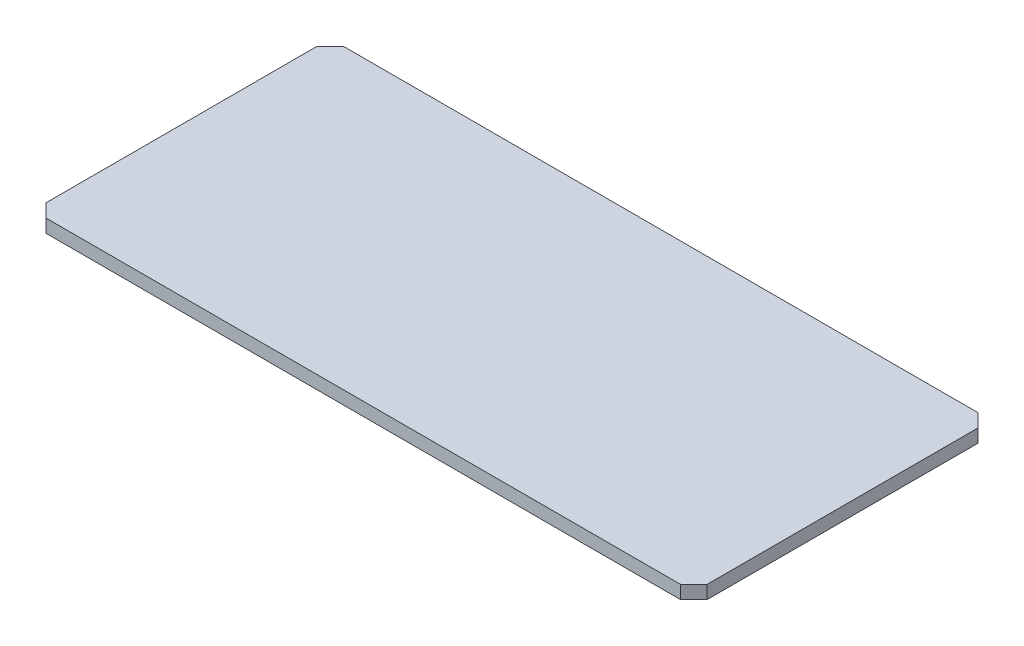
from build123d import *

# Parameters (mm, degrees)
SKETCH1_W                 = 254
SKETCH1_H                 = 114.3
BOSS_EXTRUDE1_DEPTH       = 5.08
CHAMFER1_SIZE             = 5.08
BOSS_EXTRUDE3_START       = -127
BOSS_EXTRUDE3_DEPTH       = 38.1
BOSS_EXTRUDE4_DEPTH       = 2.54
SKETCH6_R                 = 3
BOSS_EXTRUDE5_DEPTH       = 6
SKETCH12_R                = 3
SKETCH12_R_2              = 3.5
BOSS_EXTRUDE7_DEPTH       = 6
F_3_0MM_DOWEL_HOLE1_D     = 3
F_3_0MM_DOWEL_HOLE1_DEPTH = 5.08
SKETCH13_W                = 114.3
SKETCH13_H                = 11.500997776
CUT_EXTRUDE1_DEPTH        = 255


with BuildPart() as part:
    # Sketch1 → Boss-Extrude1 (new body)
    with BuildSketch(Plane(origin=(0, 0, 0), x_dir=(1, 0, 0), z_dir=(0, 1, 0))):
        with Locations((-127, 57.15)):
            Rectangle(SKETCH1_W, SKETCH1_H)
    extrude(amount=BOSS_EXTRUDE1_DEPTH)

    # Chamfer1
    chamfer1_edges = [part.edges().sort_by_distance(p)[0] for p in [
        (0, 2.54, 0),
        (-254, 2.54, 0),
        (-254, 2.54, -114.3),
        (0, 2.54, -114.3),
    ]]
    chamfer(chamfer1_edges, length=CHAMFER1_SIZE)

    # Sketch3 → Boss-Extrude3 (add, symmetric)
    with BuildSketch(Plane(origin=(0, 0, 0), x_dir=(0, 0, -1), z_dir=(1, 0, 0)).offset(BOSS_EXTRUDE3_START)):
        Polygon((2.667, 5.08), (2.667, 6.35), (2.032, 7.62), (2.667, 8.89), (3.937, 8.89), (3.937, 5.08), align=None)
    boss_extrude3 = extrude(amount=BOSS_EXTRUDE3_DEPTH, both=True)

    # Mirror1: Boss-Extrude3 across plane
    add(boss_extrude3.mirror(Plane.XY.offset(-57.15)))

    # Sketch4 → Boss-Extrude4 (add)
    with BuildSketch(Plane(origin=(0, 5.08, 0), x_dir=(1, 0, 0), z_dir=(0, 1, 0))):
        Polygon((-6.184707571, 111.633), (-247.815292429, 111.633), (-251.333, 108.115292429), (-251.333, 6.184707571), (-247.815292429, 2.667), (-6.184707571, 2.667), (-2.667, 6.184707571), (-2.667, 108.115292429), align=None)
        Polygon((-7.247331044, 109.0676), (-246.752668956, 109.0676), (-248.7676, 107.052668956), (-248.7676, 7.247331044), (-246.752668956, 5.2324), (-7.247331044, 5.2324), (-5.2324, 7.247331044), (-5.2324, 107.052668956), align=None, mode=Mode.SUBTRACT)
    extrude(amount=BOSS_EXTRUDE4_DEPTH)

    # Sketch6 → Boss-Extrude5 (add)
    with BuildSketch(Plane(origin=(0, 5.08, 0), x_dir=(1, 0, 0), z_dir=(0, 1, 0))):
        with Locations((-30.6324, 67.31)):
            Circle(SKETCH6_R)
        with Locations((-30.6324, 19.05)):
            Circle(SKETCH6_R)
        with Locations((-82.7024, 52.07)):
            Circle(SKETCH6_R)
        with Locations((-82.7024, 24.13)):
            Circle(SKETCH6_R)
    extrude(amount=BOSS_EXTRUDE5_DEPTH)

    # Sketch12 → Boss-Extrude7 (add)
    with BuildSketch(Plane(origin=(0, 5.08, 0), x_dir=(1, 0, 0), z_dir=(0, 1, 0))):
        with Locations((-132.2324, 67.4624)):
            Circle(SKETCH12_R)
        with Locations((-132.2324, 11.5824)):
            Circle(SKETCH12_R)
        with Locations((-113.1824, 67.4624)):
            Circle(SKETCH12_R)
        with Locations((-113.1824, 11.5824)):
            Circle(SKETCH12_R)
        with Locations((-81.4324, 96.3676)):
            Circle(SKETCH12_R_2)
        with Locations((-171.4324, 96.3676)):
            Circle(SKETCH12_R_2)
    extrude(amount=BOSS_EXTRUDE7_DEPTH)

    # Ø3.0mm Dowel Hole1
    with Locations(Plane(origin=(0, 11.08, 0), x_dir=(1, 0, 0), z_dir=(0, 1, 0))):
        with Locations((-82.7024, 24.13), (-82.7024, 52.07), (-30.6324, 67.31), (-30.6324, 19.05), (-132.2324, 11.5824), (-113.1824, 11.5824), (-171.4324, 96.3676), (-132.2324, 67.4624), (-113.1824, 67.4624), (-81.4324, 96.3676)):
            Hole(F_3_0MM_DOWEL_HOLE1_D / 2, depth=F_3_0MM_DOWEL_HOLE1_DEPTH)

    # Sketch13 → Cut-Extrude1 (cut, through all)
    with BuildSketch(Plane.ZY.offset(254)):
        with Locations((-57.15, 10.830498888)):
            Rectangle(SKETCH13_W, SKETCH13_H)
    extrude(amount=-CUT_EXTRUDE1_DEPTH, mode=Mode.SUBTRACT)


solid = part.part
